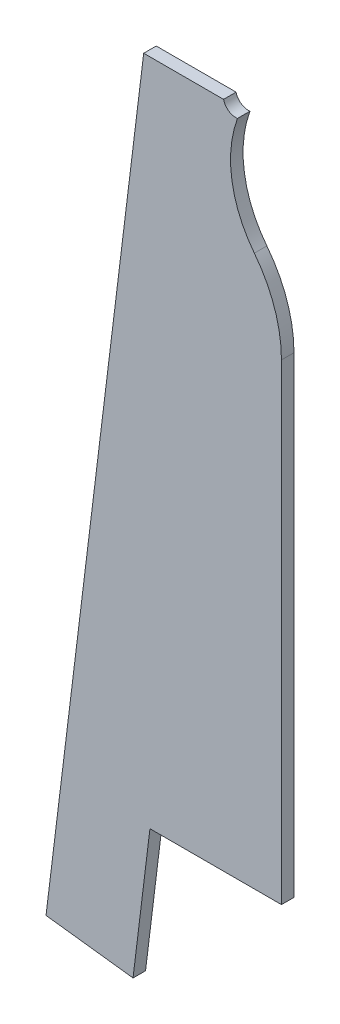
from build123d import *

# Parameters (mm, degrees)
BOSS_EXTRUDE1_DEPTH = 6.35
SKETCH2_R           = 6.35
CUT_EXTRUDE1_DEPTH  = 6.35
CUT_EXTRUDE4_DEPTH  = 6.35


with BuildPart() as part:
    # Sketch1 → Boss-Extrude1 (new body)
    with BuildSketch(Plane.XY):
        Polygon((20.505148302, 25.897062134), (-23.613528139, 31.314154449), (25.914173021, 434.684910476), (95.764173021, 434.684910476), (95.764173021, 95.747062134), (29.081649881, 95.747062134), align=None)
    extrude(amount=BOSS_EXTRUDE1_DEPTH)

    # Sketch2 → Cut-Extrude1 (cut)
    with BuildSketch(Plane.XY.offset(6.35)):
        with Locations((72.594859494, 436.135448726)):
            Circle(SKETCH2_R)
    extrude(amount=-CUT_EXTRUDE1_DEPTH, mode=Mode.SUBTRACT)

    # Sketch4 → Cut-Extrude4 (cut)
    with BuildSketch(Plane.XY.offset(6.35)):
        with BuildLine():
            Line((74.295018445, 431.943320697), (82.016159891, 440.361424689))
            Line((82.016159891, 440.361424689), (105.989857785, 438.164600241))
            Line((105.989857785, 438.164600241), (95.764173021, 334.935994434))
            ThreePointArc((95.764173021, 334.935994434), (92.231289046, 356.088107858), (82.016159891, 374.943990437))
            ThreePointArc((82.016159891, 374.943990437), (70.461962448, 402.401475249), (74.295018445, 431.943320697))
        make_face()
    extrude(amount=-CUT_EXTRUDE4_DEPTH, mode=Mode.SUBTRACT)


solid = part.part
